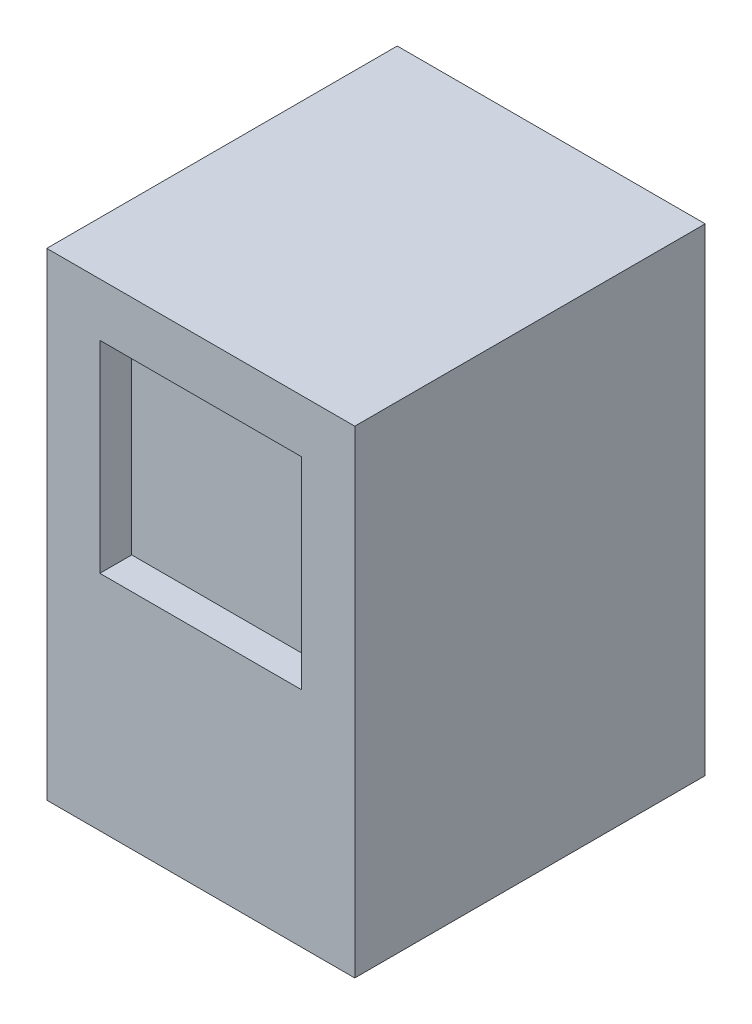
from build123d import *

# Parameters (mm, degrees)
SKETCH1_W           = 736.6
SKETCH1_H           = 838.2
BOSS_EXTRUDE1_DEPTH = 1143
SKETCH3_W           = 482.6
SKETCH3_H           = 482.6
CUT_EXTRUDE1_DEPTH  = 76.2


with BuildPart() as part:
    # Sketch1 → Boss-Extrude1 (new body)
    with BuildSketch(Plane(origin=(0, 0, 0), x_dir=(1, 0, 0), z_dir=(0, 1, 0))):
        Rectangle(SKETCH1_W, SKETCH1_H)
    extrude(amount=BOSS_EXTRUDE1_DEPTH)

    # Sketch3 → Cut-Extrude1 (cut)
    with BuildSketch(Plane.XY.offset(419.1)):
        with Locations((0, 774.7)):
            Rectangle(SKETCH3_W, SKETCH3_H)
    extrude(amount=-CUT_EXTRUDE1_DEPTH, mode=Mode.SUBTRACT)


solid = part.part
